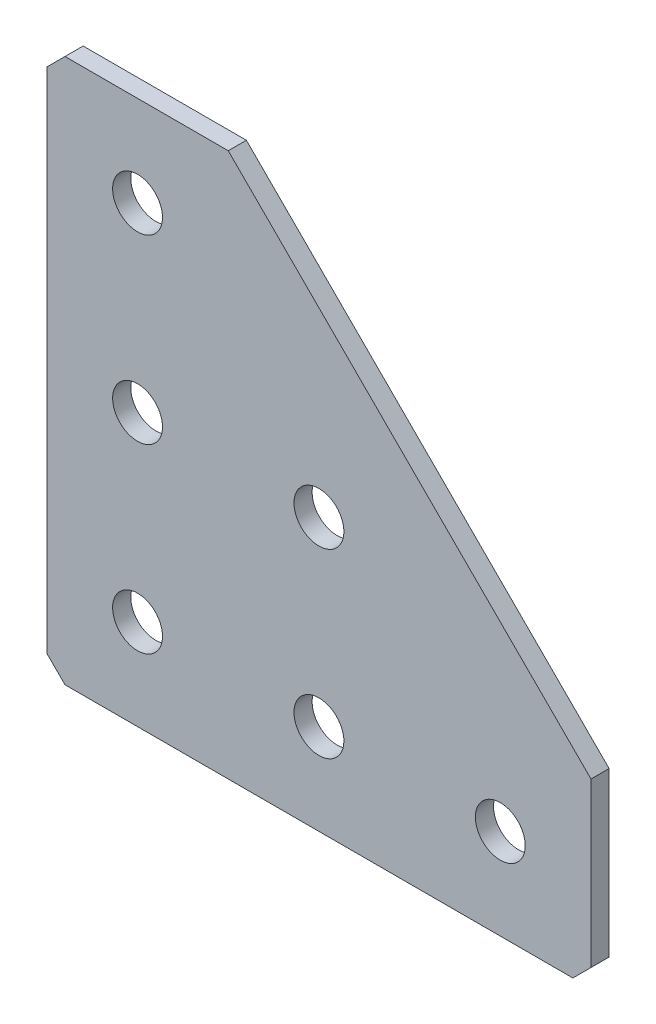
from build123d import *

# Parameters (mm, degrees)
EXTRUDE_1_DEPTH   = 2
HOLE_WIZARD_M51_D = 5.5
CHAMFER_1_SIZE    = 2


with BuildPart() as part:
    # Эскиз1 → Бобышка-Вытянуть1 (new body)
    with BuildSketch(Plane(origin=(0, 0, 0), x_dir=(1, 0, 0), z_dir=(0, 0, -1))):
        Polygon((0, 0), (0, 60), (60, 60), (60, 40), (20, 0), align=None)
    extrude(amount=EXTRUDE_1_DEPTH)

    # Отверстие с зазором M51 (through all)
    with Locations(Plane(origin=(0, 0, -2), x_dir=(1, 0, 0), z_dir=(0, 0, -1))):
        with Locations((30, 50), (10, 50), (10, 30), (10, 10), (50, 50), (30, 30)):
            Hole(HOLE_WIZARD_M51_D / 2)

    # Фаска1
    chamfer_1_edges = [part.edges().sort_by_distance(p)[0] for p in [
        (0, 0, -1),
        (0, -60, -1),
        (60, -60, -1),
    ]]
    chamfer(chamfer_1_edges, length=CHAMFER_1_SIZE)


solid = part.part
